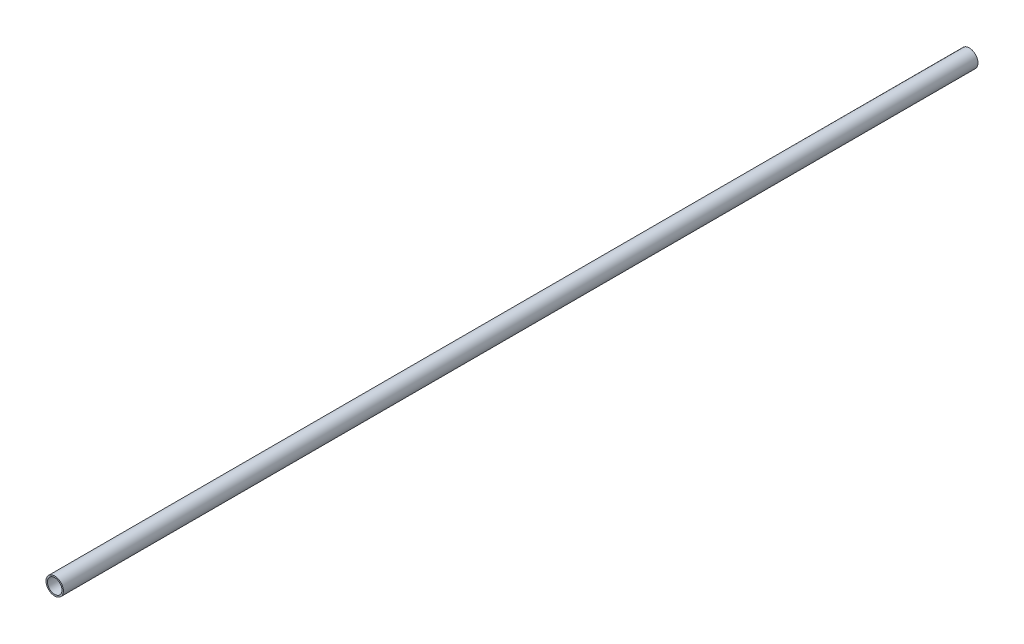
from build123d import *

# Parameters (mm, degrees)
SKETCH1_R           = 9.525
SKETCH1_R_2         = 7.9375
BOSS_EXTRUDE1_DEPTH = 1000.125


with BuildPart() as part:
    # Sketch1 → Boss-Extrude1 (new body)
    with BuildSketch(Plane.XY):
        Circle(SKETCH1_R)
        Circle(SKETCH1_R_2, mode=Mode.SUBTRACT)
    extrude(amount=BOSS_EXTRUDE1_DEPTH)


solid = part.part
